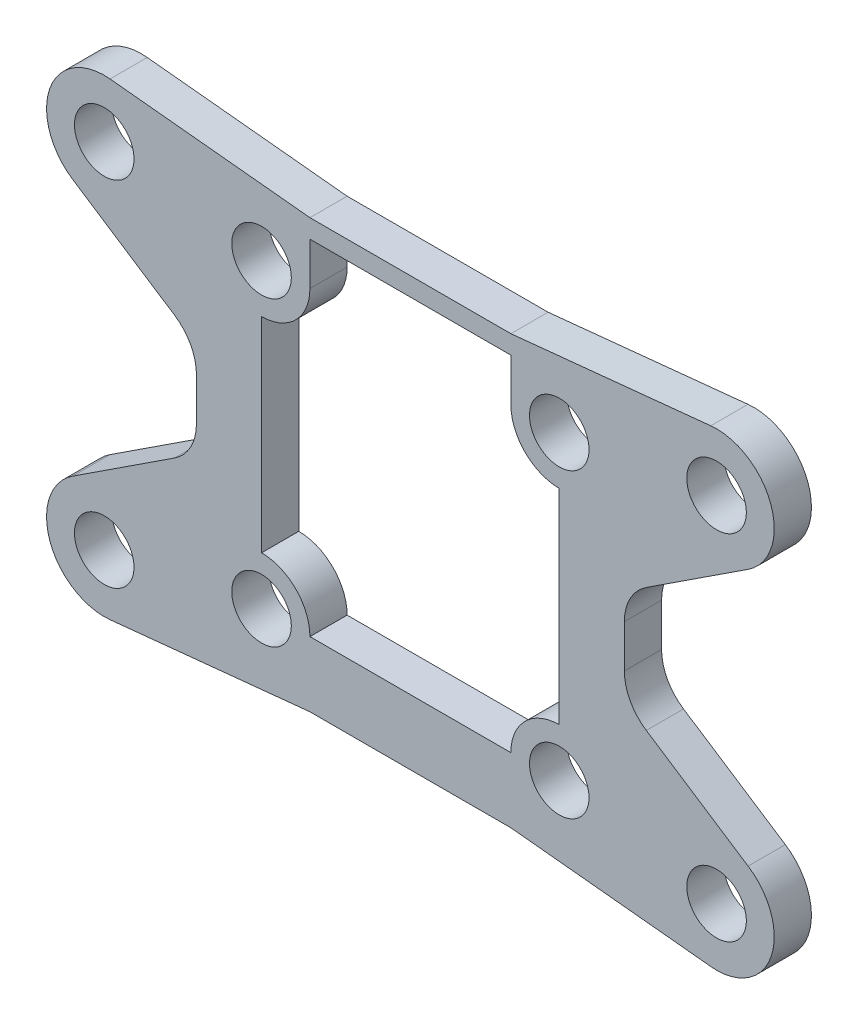
from build123d import *

# Parameters (mm, degrees)
SKETCH1_W             = 23
SKETCH1_H             = 23
BOSS_EXTRUDE1_DEPTH   = 2
FILLET1_R             = 2
SKETCH2_R             = 1.6
CUT_EXTRUDE1_DEPTH    = 2
SKETCH3_W             = 10.8
SKETCH3_H             = 2.3
CUT_EXTRUDE2_DEPTH    = 2
SKETCH5_R             = 1.6
BOSS_EXTRUDE2_DEPTH   = 2
BOSS_EXTRUDE2_2_DEPTH = 2
BOSS_EXTRUDE2_3_DEPTH = 2
BOSS_EXTRUDE2_4_DEPTH = 2


with BuildPart() as part:
    # Sketch1 → Boss-Extrude1 (new body)
    with BuildSketch(Plane.XY):
        with Locations((11.5, 11.5)):
            Rectangle(SKETCH1_W, SKETCH1_H)
    extrude(amount=BOSS_EXTRUDE1_DEPTH)

    # Fillet1
    fillet1_edges = [part.edges().sort_by_distance(p)[0] for p in [
        (0, 23, 1),
        (23, 23, 1),
        (23, 0, 1),
        (0, 0, 1),
    ]]
    fillet(fillet1_edges, radius=FILLET1_R)

    # Sketch2 → Cut-Extrude1 (cut)
    with BuildSketch(Plane.XY):
        with Locations((3.5, 19.7)):
            Circle(SKETCH2_R)
        with Locations((19.5, 19.7)):
            Circle(SKETCH2_R)
        with Locations((19.5, 3.5)):
            Circle(SKETCH2_R)
        with Locations((3.5, 3.5)):
            Circle(SKETCH2_R)
        with BuildLine():
            Line((3.5, 17.1), (3.5, 6.1))
            ThreePointArc((3.5, 6.1), (5.338477631, 5.338477631), (6.1, 3.5))
            Line((6.1, 3.5), (16.9, 3.5))
            ThreePointArc((16.9, 3.5), (17.661522369, 5.338477631), (19.5, 6.1))
            Line((19.5, 6.1), (19.5, 17.1))
            ThreePointArc((19.5, 17.1), (17.661522369, 17.861522369), (16.9, 19.7))
            Line((16.9, 19.7), (6.1, 19.7))
            ThreePointArc((6.1, 19.7), (5.338477631, 17.861522369), (3.5, 17.1))
        make_face()
    extrude(amount=CUT_EXTRUDE1_DEPTH, mode=Mode.SUBTRACT)

    # Sketch3 → Cut-Extrude2 (cut)
    with BuildSketch(Plane.XY):
        with Locations((11.5, 20.85)):
            Rectangle(SKETCH3_W, SKETCH3_H)
    extrude(amount=CUT_EXTRUDE2_DEPTH, mode=Mode.SUBTRACT)


with BuildPart() as body_2:
    # Sketch5 → Boss-Extrude2 (new body)
    with BuildSketch(Plane.XY):
        with BuildLine():
            Line((16.9, 23), (21.776453683, 21.561960094))
            Line((21.776453683, 21.561960094), (23, 12.648059803))
            ThreePointArc((23, 12.648059803), (23.313519219, 13.886650017), (24.17856315, 14.826915413))
            Line((24.17856315, 14.826915413), (29.65108056, 18.405475842))
            ThreePointArc((29.65108056, 18.405475842), (30.877170115, 22.033391556), (27.643175365, 24.084329386))
            Line((27.643175365, 24.084329386), (16.9, 23))
        make_face()
        with Locations((27.954482672, 21)):
            Circle(SKETCH5_R, mode=Mode.SUBTRACT)
    extrude(amount=BOSS_EXTRUDE2_DEPTH)


with BuildPart() as body_3:
    # Sketch5 → Boss-Extrude2 2 (new body)
    with BuildSketch(Plane.XY):
        with BuildLine():
            Line((-4.643175365, 24.084329386), (6.1, 23))
            Line((6.1, 23), (1.223546317, 21.561960094))
            Line((1.223546317, 21.561960094), (0, 12.648059803))
            ThreePointArc((0, 12.648059803), (-0.313519219, 13.886650017), (-1.17856315, 14.826915413))
            Line((-1.17856315, 14.826915413), (-6.65108056, 18.405475842))
            ThreePointArc((-6.65108056, 18.405475842), (-7.877170115, 22.033391556), (-4.643175365, 24.084329386))
        make_face()
        with Locations((-4.954482672, 21)):
            Circle(SKETCH5_R, mode=Mode.SUBTRACT)
    extrude(amount=BOSS_EXTRUDE2_2_DEPTH)


with BuildPart() as body_4:
    # Sketch5 → Boss-Extrude2 3 (new body)
    with BuildSketch(Plane.XY):
        with BuildLine():
            Line((16.9, 0), (21.776453683, 1.438039906))
            Line((21.776453683, 1.438039906), (23, 10.351940197))
            ThreePointArc((23, 10.351940197), (23.313519219, 9.113349983), (24.17856315, 8.173084587))
            Line((24.17856315, 8.173084587), (29.65108056, 4.594524158))
            ThreePointArc((29.65108056, 4.594524158), (30.877170115, 0.966608444), (27.643175365, -1.084329386))
            Line((27.643175365, -1.084329386), (16.9, 0))
        make_face()
        with Locations((27.954482672, 2)):
            Circle(SKETCH5_R, mode=Mode.SUBTRACT)
    extrude(amount=BOSS_EXTRUDE2_3_DEPTH)


with BuildPart() as body_5:
    # Sketch5 → Boss-Extrude2 4 (new body)
    with BuildSketch(Plane.XY):
        with BuildLine():
            Line((6.1, 0), (1.223546317, 1.438039906))
            Line((1.223546317, 1.438039906), (0, 10.351940197))
            ThreePointArc((0, 10.351940197), (-0.313519219, 9.113349983), (-1.17856315, 8.173084587))
            Line((-1.17856315, 8.173084587), (-6.65108056, 4.594524158))
            ThreePointArc((-6.65108056, 4.594524158), (-7.877170115, 0.966608444), (-4.643175365, -1.084329386))
            Line((-4.643175365, -1.084329386), (6.1, 0))
        make_face()
        with Locations((-4.954482672, 2)):
            Circle(SKETCH5_R, mode=Mode.SUBTRACT)
    extrude(amount=BOSS_EXTRUDE2_4_DEPTH)

    # Combine1: union part, body 3, body 2, body 4
    add(part.part)
    add(body_3.part)
    add(body_2.part)
    add(body_4.part)


solid = body_5.part
